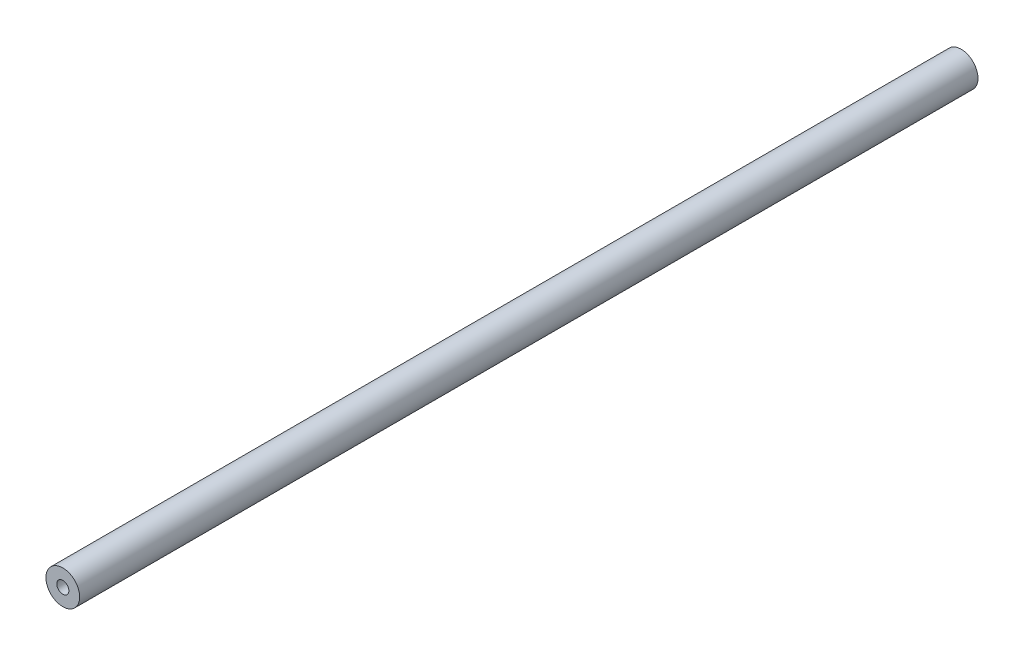
from build123d import *

# Parameters (mm, degrees)
SKETCH1_R           = 6
BOSS_EXTRUDE1_DEPTH = 320
SKETCH2_R           = 2.15
CUT_EXTRUDE1_DEPTH  = 20
SKETCH3_R           = 2.15
CUT_EXTRUDE2_DEPTH  = 20


with BuildPart() as part:
    # Sketch1 → Boss-Extrude1 (new body)
    with BuildSketch(Plane.XY):
        Circle(SKETCH1_R)
    extrude(amount=BOSS_EXTRUDE1_DEPTH)

    # Sketch2 → Cut-Extrude1 (cut)
    with BuildSketch(Plane.XY.offset(320)):
        Circle(SKETCH2_R)
    extrude(amount=-CUT_EXTRUDE1_DEPTH, mode=Mode.SUBTRACT)

    # Sketch3 → Cut-Extrude2 (cut)
    with BuildSketch(Plane(origin=(0, 0, 0), x_dir=(-1, 0, 0), z_dir=(0, 0, -1))):
        Circle(SKETCH3_R)
    extrude(amount=-CUT_EXTRUDE2_DEPTH, mode=Mode.SUBTRACT)


solid = part.part
